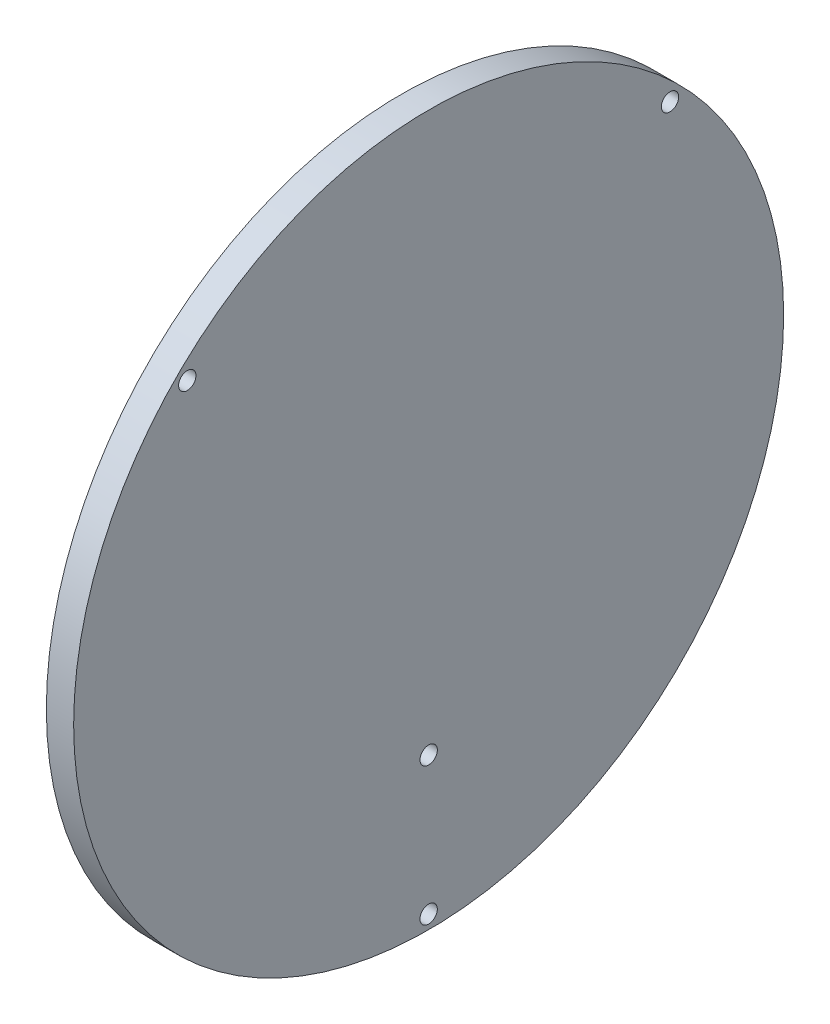
from build123d import *

# Parameters (mm, degrees)
SKETCH1_R                         = 260
BOSS_EXTRUDE1_DEPTH               = 20
F_1_2_13_TAPPED_HOLE1_D           = 10.71626
F_1_2_13_TAPPED_HOLE1_DEPTH       = 70.4
F_1_2_13_TAPPED_HOLE1_CBORE_D     = 12.7
F_1_2_13_TAPPED_HOLE1_CBORE_DEPTH = 64.5
F_1_2_13_TAPPED_HOLE1_TIP         = 3.219489309


with BuildPart() as part:
    # Sketch1 → Boss-Extrude1 (new body)
    with BuildSketch(Plane(origin=(0, 0, 0), x_dir=(0, 0, -1), z_dir=(1, 0, 0))):
        Circle(SKETCH1_R)
    extrude(amount=BOSS_EXTRUDE1_DEPTH)

    # 1/2-13 Tapped Hole1
    with Locations(Plane(origin=(20, 176.776695297, 176.776695297), x_dir=(0, 0, 1), z_dir=(1, 0, 0))):
        with Locations((0, 0), (-353.553390594, 0), (-176.776695297, 426.776695297), (-176.776695297, 325.879201874)):
            CounterBoreHole(F_1_2_13_TAPPED_HOLE1_D / 2, F_1_2_13_TAPPED_HOLE1_CBORE_D / 2, F_1_2_13_TAPPED_HOLE1_CBORE_DEPTH, depth=F_1_2_13_TAPPED_HOLE1_DEPTH)
            with Locations((0, 0, -(F_1_2_13_TAPPED_HOLE1_DEPTH + F_1_2_13_TAPPED_HOLE1_TIP / 2))):  # 118° drill point
                Cone(0, F_1_2_13_TAPPED_HOLE1_D / 2, F_1_2_13_TAPPED_HOLE1_TIP, mode=Mode.SUBTRACT)


solid = part.part
